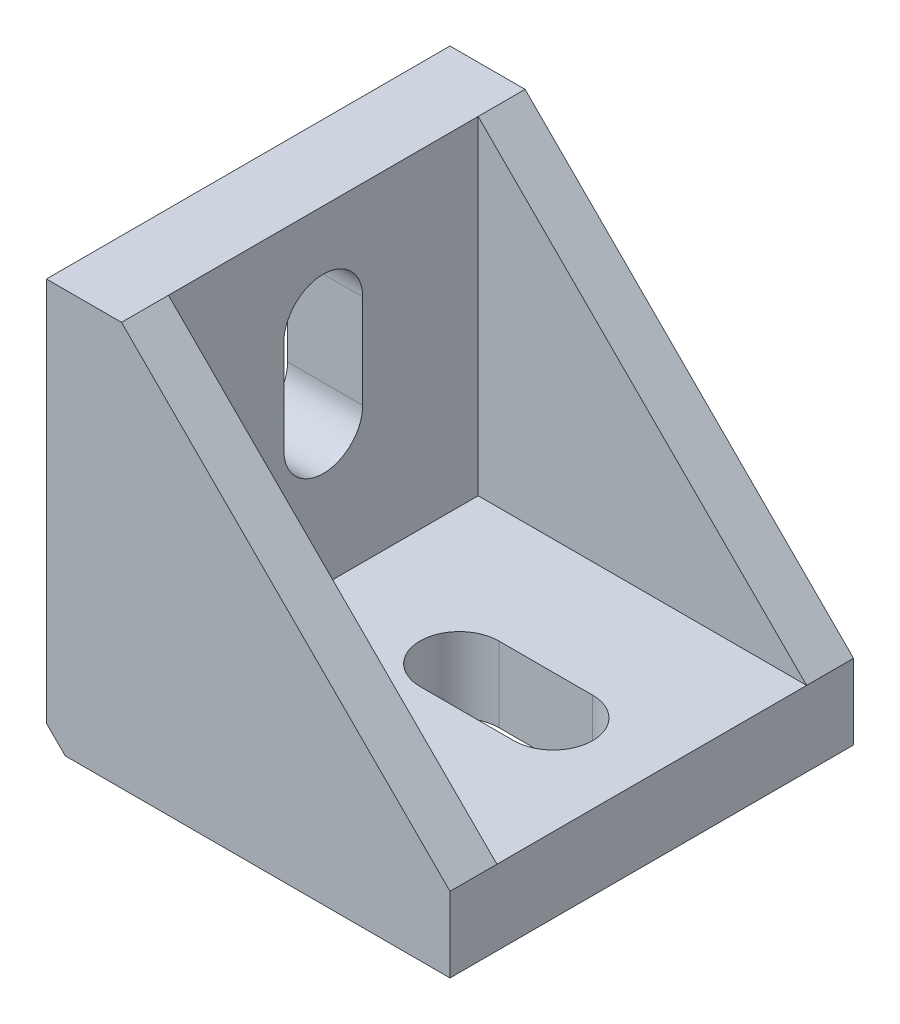
from build123d import *

# Parameters (mm, degrees)
BOSS_EXTRU_1_DEPTH           = 43
ENL_V_MAT_EXTRU_1_DEPTH      = 16.5
ENL_V_MAT_EXTRU_2_DEPTH      = 36
ENL_V_MAT_EXTRU_2_DEPTH_BACK = 9
ENL_V_MAT_EXTRU_3_DEPTH      = 9
CHANFREIN1_SIZE              = 2


with BuildPart() as part:
    # Esquisse1 → Boss.-Extru.1 (new body)
    with BuildSketch(Plane.XY):
        Polygon((0, 43), (0, 0), (43, 0), (43, 8), (8, 43), align=None)
    extrude(amount=BOSS_EXTRU_1_DEPTH)

    # Esquisse2 → Enlèv. mat.-Extru.1 (cut, symmetric)
    with BuildSketch(Plane.XY.offset(21.5)):
        Polygon((8, 43.558751445), (8, 8), (47.774907193, 8), (49.427845989, 41.515592143), align=None)
    extrude(amount=ENL_V_MAT_EXTRU_1_DEPTH, both=True, mode=Mode.SUBTRACT)

    # Esquisse3 → Enlèv. mat.-Extru.2 (cut, two sides)
    with BuildSketch(Plane(origin=(8, 0, 0), x_dir=(0, 0, -1), z_dir=(1, 0, 0))) as enl_v_mat_extru_2_sk:
        with BuildLine():
            Line((-25.7, 22.5), (-25.7, 32.5))
            ThreePointArc((-25.7, 32.5), (-21.5, 36.7), (-17.3, 32.5))
            Line((-17.3, 32.5), (-17.3, 22.5))
            ThreePointArc((-17.3, 22.5), (-21.5, 18.3), (-25.7, 22.5))
        make_face()
    extrude(amount=ENL_V_MAT_EXTRU_2_DEPTH, mode=Mode.SUBTRACT)
    extrude(enl_v_mat_extru_2_sk.sketch, amount=-ENL_V_MAT_EXTRU_2_DEPTH_BACK, mode=Mode.SUBTRACT)

    # Esquisse4 → Enlèv. mat.-Extru.3 (cut, through all)
    with BuildSketch(Plane(origin=(0, 8, 0), x_dir=(1, 0, 0), z_dir=(0, 1, 0))):
        with BuildLine():
            Line((32.5, -25.7), (22.5, -25.7))
            ThreePointArc((22.5, -25.7), (18.3, -21.5), (22.5, -17.3))
            Line((22.5, -17.3), (32.5, -17.3))
            ThreePointArc((32.5, -17.3), (36.7, -21.5), (32.5, -25.7))
        make_face()
    extrude(amount=-ENL_V_MAT_EXTRU_3_DEPTH, mode=Mode.SUBTRACT)

    # Chanfrein1
    chanfrein1_edges = [part.edges().sort_by_distance(p)[0] for p in [
        (0, 0, 21.5),
    ]]
    chamfer(chanfrein1_edges, length=CHANFREIN1_SIZE)


solid = part.part
